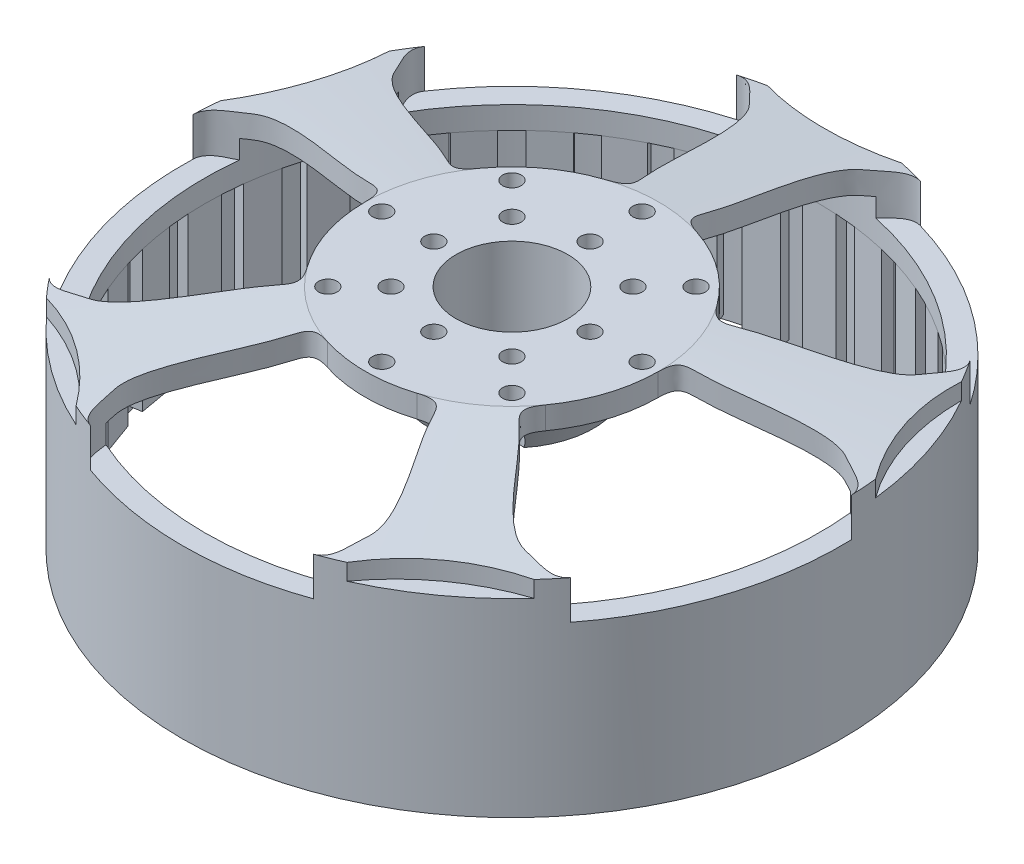
from build123d import *

# Parameters (mm, degrees)
SKIZZE1_R                       = 44.3
AUFSATZ_LINEAR_AUSTRAGEN1_DEPTH = 30.5
SKIZZE2_R                       = 14
AUFSATZ_LINEAR_AUSTRAGEN2_DEPTH = 4
FASE1_SIZE                      = 2.8
FASE1_SIZE2                     = 24.575284599
WANDUNG1_T                      = -3
SCHNITT_LINEAR_AUSTRAGEN1_DEPTH = 8
KREISMUSTER1_COUNT              = 5
SCHNITT_LINEAR_AUSTRAGEN2_DEPTH = 5
KREISMUSTER2_COUNT              = 5
SKIZZE5_R                       = 42.8
SKIZZE5_R_2                     = 41.3
SCHNITT_LINEAR_AUSTRAGEN3_DEPTH = 19.5
AUFSATZ_LINEAR_AUSTRAGEN3_DEPTH = 19
KREISMUSTER3_COUNT              = 36
SKIZZE7_R                       = 14
SCHNITT_LINEAR_AUSTRAGEN4_DEPTH = 4
M3_GEWINDEBOHRUNG1_D            = 2.5
KREISMUSTER4_COUNT              = 8
KREISMUSTER5_COUNT              = 4
KREISMUSTER6_COUNT              = 4


with BuildPart() as part:
    # Skizze1 → Aufsatz-Linear austragen1 (new body)
    with BuildSketch(Plane(origin=(0, 0, 0), x_dir=(1, 0, 0), z_dir=(0, 1, 0))):
        with Locations(Location((0, 0, 0), (0, 0, 270))):
            Circle(SKIZZE1_R)
    extrude(amount=-AUFSATZ_LINEAR_AUSTRAGEN1_DEPTH)

    # Skizze2 → Aufsatz-Linear austragen2 (add)
    with BuildSketch(Plane(origin=(0, 0, 0), x_dir=(1, 0, 0), z_dir=(0, 1, 0))):
        with Locations(Location((0, 0, 0), (0, 0, 270))):
            Circle(SKIZZE2_R)
    extrude(amount=AUFSATZ_LINEAR_AUSTRAGEN2_DEPTH)

    # Fase1
    fase1_edges = [part.edges().sort_by_distance(p)[0] for p in [
        (0, 0, -44.3),
    ]]
    fase1_side = [part.faces().sort_by_distance(p)[0] for p in [
        (0, -15.25, -44.3),
    ]]
    chamfer(fase1_edges, length=FASE1_SIZE, length2=FASE1_SIZE2, reference=fase1_side[0])

    # Wandung1
    wandung1_openings = [part.faces().sort_by_distance(p)[0] for p in [
        (0, -30.5, 0),
    ]]
    offset(amount=WANDUNG1_T, openings=wandung1_openings, kind=Kind.INTERSECTION)

    # Skizze3 → Schnitt-Linear austragen1 (cut)
    with BuildSketch(Plane(origin=(0, 0, 0), x_dir=(1, 0, 0), z_dir=(0, 1, 0))):
        with BuildLine():
            ThreePointArc((-6, -18.79000792), (0, -19.724715401), (6, -18.79000792))
            add(Edge.make_bspline(
                [(6, -18.79000792), (9.000728971, -17.83181919), (8.856570125, -19.390171595), (13.243012056, -26.802107429), (17.765147204, -33.543113487), (16.708303218, -38.129474323), (16.693674449, -41.073729236), (15, -41.683210049)],
                knots=[0, 0, 0, 0, 0.318772192, 0.39998146, 0.766302549, 0.830883416, 1, 1, 1, 1], degree=3))
            ThreePointArc((15, -41.683210049), (0, -44.3), (-15, -41.683210049))
            add(Edge.make_bspline(
                [(-6, -18.79000792), (-9.000728971, -17.83181919), (-8.856570125, -19.390171595), (-13.243012056, -26.802107429), (-17.765147204, -33.543113487), (-16.708303218, -38.129474323), (-16.693674449, -41.073729236), (-15, -41.683210049)],
                knots=[0, 0, 0, 0, 0.318772192, 0.39998146, 0.766302549, 0.830883416, 1, 1, 1, 1], degree=3))
        make_face()
    schnitt_linear_austragen1 = extrude(amount=-SCHNITT_LINEAR_AUSTRAGEN1_DEPTH, mode=Mode.SUBTRACT)

    # Kreismuster1: Schnitt-Linear austragen1 ×5 about axis
    kreismuster1_axis = Axis((0, 0, 0), (0, 1, 0))
    for i in range(1, KREISMUSTER1_COUNT):
        add(schnitt_linear_austragen1.rotate(kreismuster1_axis, i * 360 / KREISMUSTER1_COUNT), mode=Mode.SUBTRACT)

    # Skizze4 → Schnitt-Linear austragen2 (cut)
    with BuildSketch(Plane(origin=(0, 0, 0), x_dir=(1, 0, 0), z_dir=(0, 1, 0))):
        with BuildLine():
            ThreePointArc((-9, 43.376145518), (0, 44.3), (9, 43.376145518))
            ThreePointArc((9, 43.376145518), (0, 41.944243022), (-9, 43.376145518))
        make_face()
    schnitt_linear_austragen2 = extrude(amount=-SCHNITT_LINEAR_AUSTRAGEN2_DEPTH, mode=Mode.SUBTRACT)

    # Kreismuster2: Schnitt-Linear austragen2 ×5 about axis
    kreismuster2_axis = Axis((0, 0, 0), (0, 1, 0))
    for i in range(1, KREISMUSTER2_COUNT):
        add(schnitt_linear_austragen2.rotate(kreismuster2_axis, i * 360 / KREISMUSTER2_COUNT), mode=Mode.SUBTRACT)

    # Skizze5 → Schnitt-Linear austragen3 (cut)
    with BuildSketch(Plane(origin=(0, -30.5, 0), x_dir=(-1, 0, 0), z_dir=(0, -1, 0))):
        with Locations(Location((0, 0, 0), (0, 0, 90))):
            Circle(SKIZZE5_R)
        with Locations(Location((0, 0, 0), (0, 0, 245.865986166))):
            Circle(SKIZZE5_R_2, mode=Mode.SUBTRACT)
    extrude(amount=-SCHNITT_LINEAR_AUSTRAGEN3_DEPTH, mode=Mode.SUBTRACT)

    # Skizze6 → Aufsatz-Linear austragen3 (add)
    with BuildSketch(Plane(origin=(0, -11, 0), x_dir=(-1, 0, 0), z_dir=(0, -1, 0))):
        with BuildLine():
            Line((0, 42.8), (0, 41.3))
            Line((0, 41.3), (2.25, 41.3))
            Line((2.25, 41.3), (2.25, 42.740817727))
            ThreePointArc((2.25, 42.740817727), (1.125389104, 42.785201874), (0, 42.8))
        make_face()
        with BuildLine():
            Line((-2.25, 42.740817727), (-2.25, 41.3))
            Line((-2.25, 41.3), (0, 41.3))
            Line((0, 41.3), (0, 42.8))
            ThreePointArc((0, 42.8), (-1.125389104, 42.785201874), (-2.25, 42.740817727))
        make_face()
    aufsatz_linear_austragen3 = extrude(amount=AUFSATZ_LINEAR_AUSTRAGEN3_DEPTH)

    # Kreismuster3: Aufsatz-Linear austragen3 ×36 about axis
    kreismuster3_axis = Axis((0, 0, 0), (0, 1, 0))
    for i in range(1, KREISMUSTER3_COUNT):
        add(aufsatz_linear_austragen3.rotate(kreismuster3_axis, i * 360 / KREISMUSTER3_COUNT))

    # Skizze7 → Schnitt-Linear austragen4 (cut)
    with BuildSketch(Plane(origin=(0, 4, 0), x_dir=(1, 0, 0), z_dir=(0, 1, 0))):
        Circle(SKIZZE7_R)
    extrude(amount=-SCHNITT_LINEAR_AUSTRAGEN4_DEPTH, mode=Mode.SUBTRACT)

    # Skizze8 → Rotation1 (revolve)
    with BuildSketch(Plane.XY, mode=Mode.PRIVATE) as rotation1_sk:
        Polygon((-11, 0), (-7.5, 0), (-7.5, -11), (-11, -11), (-15, -3), (-11, -3), align=None)
    revolve(rotation1_sk.sketch.rotate(Axis((0, 2.779856526, 0), (0, -1, 0)), 270), axis=Axis((0, 2.779856526, 0), (0, -1, 0)))

    # M3 Gewindebohrung1 (through all)
    with Locations(Plane(origin=(0, 0, 0), x_dir=(1, 0, 0), z_dir=(0, 1, 0))):
        with Locations((0, 17.5)):
            m3_gewindebohrung1 = Hole(M3_GEWINDEBOHRUNG1_D / 2)

    # Kreismuster4: M3 Gewindebohrung1 ×8 about axis
    kreismuster4_axis = Axis((0, 0, 0), (0, 1, 0))
    for i in range(1, KREISMUSTER4_COUNT):
        add(m3_gewindebohrung1.rotate(kreismuster4_axis, i * 360 / KREISMUSTER4_COUNT), mode=Mode.SUBTRACT)

    # Skizze11 → M3 Gewindebohrung2 (revolve, cut)
    with BuildSketch(Plane(origin=(0, 0, -10.5), x_dir=(0, 0, 1), z_dir=(1, 0, 0))):
        Polygon((0, 0), (0, 8.751075774), (1.25, 8), (1.25, 0), align=None)
    m3_gewindebohrung2 = revolve(axis=Axis((0, 6.35, -10.5), (0, -1, 0)), mode=Mode.SUBTRACT)

    # Kreismuster5: M3 Gewindebohrung2 ×4 about axis
    kreismuster5_axis = Axis((0, 0, 0), (0, 1, 0))
    for i in range(1, KREISMUSTER5_COUNT):
        add(m3_gewindebohrung2.rotate(kreismuster5_axis, i * 360 / KREISMUSTER5_COUNT), mode=Mode.SUBTRACT)

    # Skizze13 → M3 Gewindebohrung3 (revolve, cut)
    with BuildSketch(Plane(origin=(-8.131727984, 0, -8.131727984), x_dir=(0, 0, 1), z_dir=(1, 0, 0))):
        Polygon((0, 0), (0, 12.251075774), (1.25, 11.5), (1.25, 0), align=None)
    m3_gewindebohrung3 = revolve(axis=Axis((-8.131727984, 6.35, -8.131727984), (0, -1, 0)), mode=Mode.SUBTRACT)

    # Kreismuster6: M3 Gewindebohrung3 ×4 about axis
    kreismuster6_axis = Axis((0, 0, 0), (0, 1, 0))
    for i in range(1, KREISMUSTER6_COUNT):
        add(m3_gewindebohrung3.rotate(kreismuster6_axis, i * 360 / KREISMUSTER6_COUNT), mode=Mode.SUBTRACT)


solid = part.part
